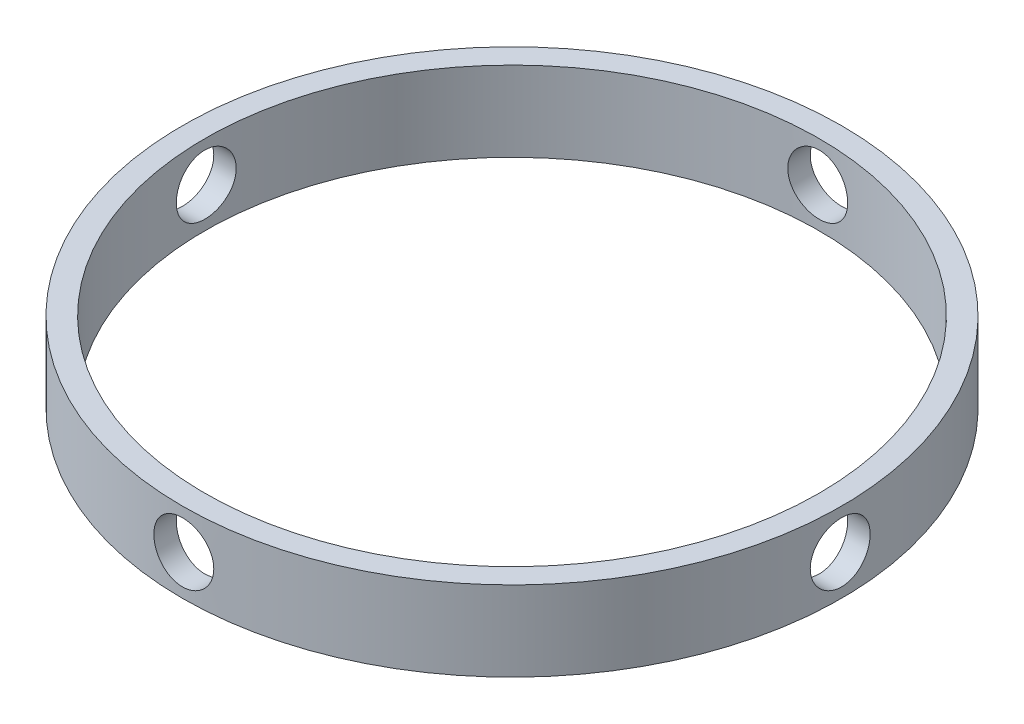
from build123d import *

# Parameters (mm, degrees)
SKETCH1_R           = 82.5
SKETCH1_R_2         = 76.9
EXTRUDE_THIN1_DEPTH = 20
SKETCH2_R           = 7.5
CUT_EXTRUDE1_DEPTH  = 100
CIRPATTERN1_COUNT   = 2
CIRPATTERN1_ANGLE   = 90


with BuildPart() as part:
    # Sketch1 → Extrude-Thin1 (new body)
    with BuildSketch(Plane(origin=(0, 0, 0), x_dir=(1, 0, 0), z_dir=(0, 1, 0))):
        Circle(SKETCH1_R)
        Circle(SKETCH1_R_2, mode=Mode.SUBTRACT)
    extrude(amount=EXTRUDE_THIN1_DEPTH)

    # Sketch2 → Cut-Extrude1 (cut, symmetric)
    with BuildSketch(Plane(origin=(0, 0, 0), x_dir=(0, 0, -1), z_dir=(1, 0, 0))):
        with Locations((0, 10)):
            Circle(SKETCH2_R)
    cut_extrude1 = extrude(amount=CUT_EXTRUDE1_DEPTH, both=True, mode=Mode.SUBTRACT)

    # CirPattern1: Cut-Extrude1 ×2 about axis
    cirpattern1_axis = Axis((0, 20, 0), (0, -1, 0))
    for i in range(1, CIRPATTERN1_COUNT):
        add(cut_extrude1.rotate(cirpattern1_axis, i * CIRPATTERN1_ANGLE / (CIRPATTERN1_COUNT - 1)), mode=Mode.SUBTRACT)


solid = part.part
